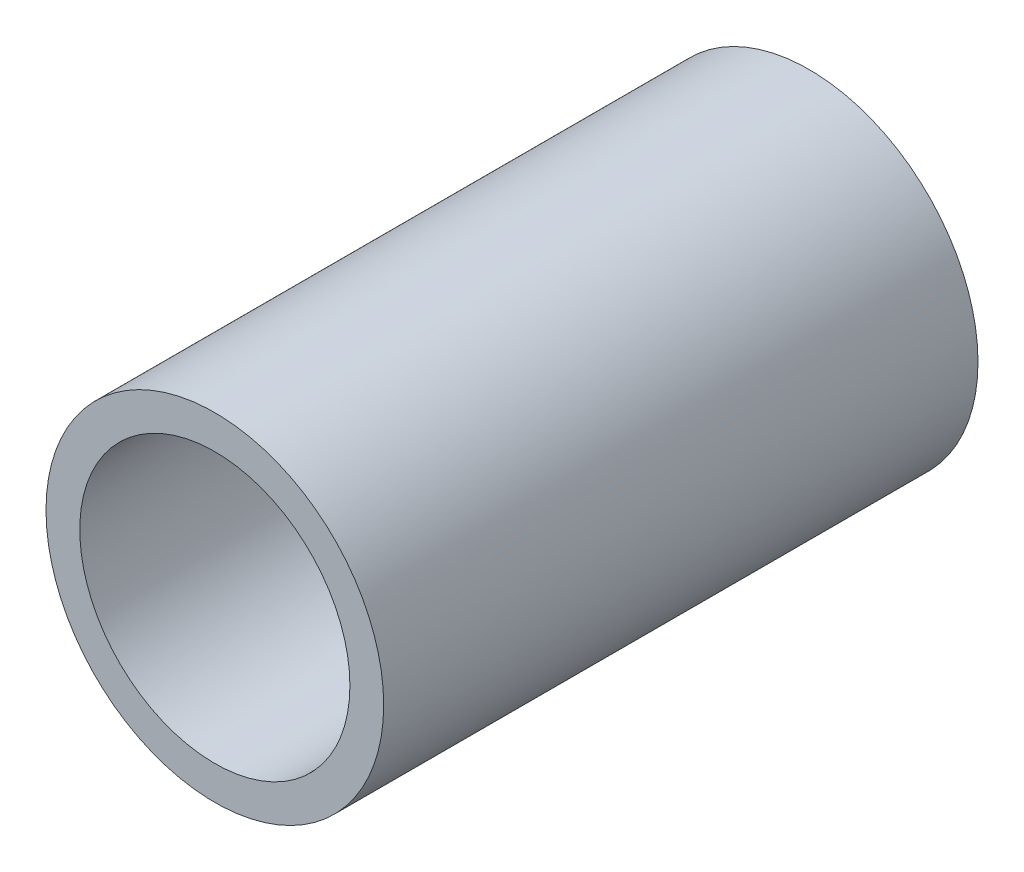
from build123d import *

# Parameters (mm, degrees)
CROQUIS2_R              = 43.75
CROQUIS2_R_2            = 35
SALIENTE_EXTRUIR6_DEPTH = 154


with BuildPart() as part:
    # Croquis2 → Saliente-Extruir6 (new body)
    with BuildSketch(Plane.XY):
        Circle(CROQUIS2_R)
        Circle(CROQUIS2_R_2, mode=Mode.SUBTRACT)
    extrude(amount=SALIENTE_EXTRUIR6_DEPTH)


solid = part.part
